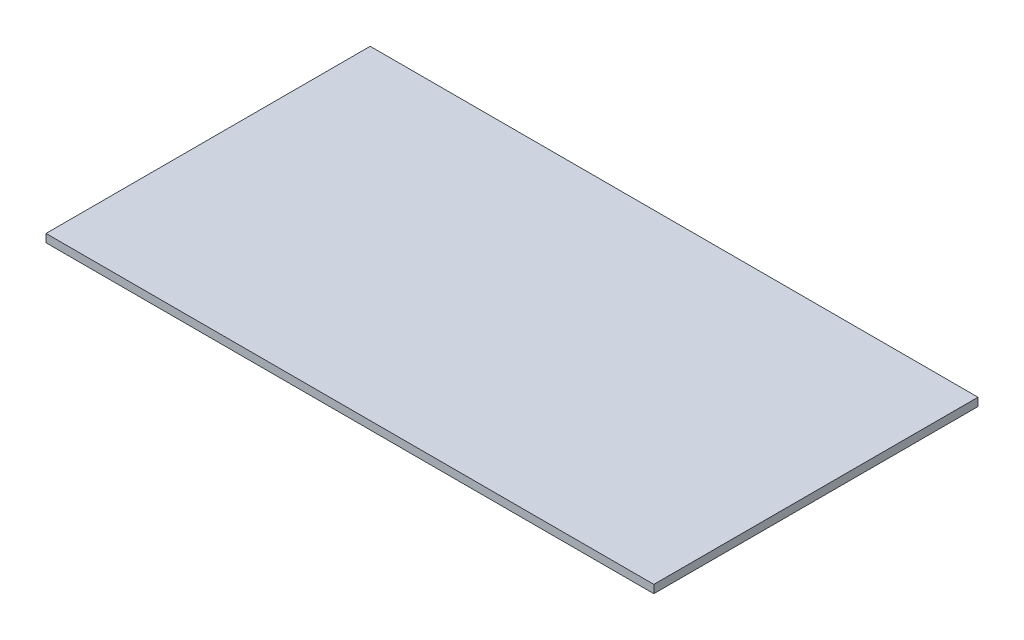
from build123d import *

# Parameters (mm, degrees)
CROQUIS1_W              = 1500
CROQUIS1_H              = 800
SALIENTE_EXTRUIR1_DEPTH = 20


with BuildPart() as part:
    # Croquis1 → Saliente-Extruir1 (new body)
    with BuildSketch(Plane(origin=(0, 0, 0), x_dir=(1, 0, 0), z_dir=(0, 1, 0))):
        Rectangle(CROQUIS1_W, CROQUIS1_H)
    extrude(amount=SALIENTE_EXTRUIR1_DEPTH)


solid = part.part
